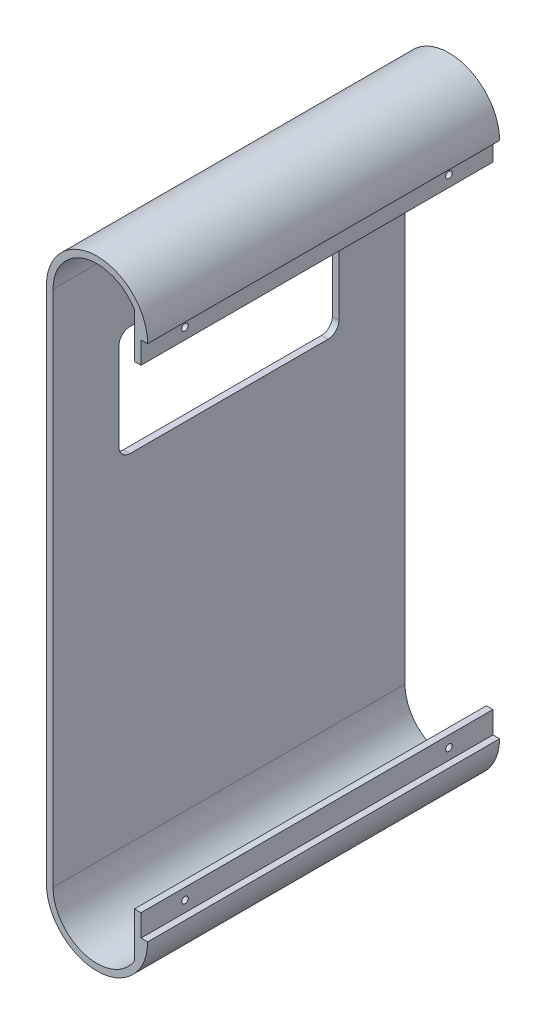
from build123d import *

# Parameters (mm, degrees)
BOSS_EXTRUDE1_DEPTH = 160
SKETCH5_W           = 3
SKETCH5_H           = 21.357816692
BOSS_EXTRUDE4_DEPTH = 160
SKETCH7_R           = 1.5
CUT_EXTRUDE2_DEPTH  = 7
CUT_EXTRUDE3_REACH  = 48


with BuildPart() as part:
    # Sketch1 → Boss-Extrude1 (new body)
    with BuildSketch(Plane.XY):
        with BuildLine():
            Line((-40, -75), (-40, 160.5))
            ThreePointArc((-40, 160.5), (-20, 180.5), (0, 160.5))
            Line((0, 160.5), (3, 160.5))
            ThreePointArc((3, 160.5), (-20, 183.5), (-43, 160.5))
            Line((-43, 160.5), (-43, -75))
            ThreePointArc((-43, -75), (-20, -98), (3, -75))
            Line((3, -75), (0, -75))
            ThreePointArc((0, -75), (-20, -95), (-40, -75))
        make_face()
    extrude(amount=-BOSS_EXTRUDE1_DEPTH)

    # Sketch5 → Boss-Extrude4 (add)
    with BuildSketch(Plane(origin=(0, 0, -160), x_dir=(-1, 0, 0), z_dir=(0, 0, -1))):
        with Locations((1.5, -75.678908346)):
            Rectangle(SKETCH5_W, SKETCH5_H)
        with Locations((1.5, 161.178908346)):
            Rectangle(SKETCH5_W, SKETCH5_H)
    extrude(amount=-BOSS_EXTRUDE4_DEPTH)

    # Sketch7 → Cut-Extrude2 (cut, through all)
    with BuildSketch(Plane.ZY.offset(3)):
        with Locations((-140, -70)):
            Circle(SKETCH7_R)
        with Locations((-20, -70)):
            Circle(SKETCH7_R)
        with Locations((-20, 155.5)):
            Circle(SKETCH7_R)
        with Locations((-140, 155.5)):
            Circle(SKETCH7_R)
    extrude(amount=-CUT_EXTRUDE2_DEPTH, mode=Mode.SUBTRACT)

    # Sketch8 → Cut-Extrude3 (cut, up to next)
    with BuildSketch(Plane.ZY.offset(43), mode=Mode.PRIVATE) as cut_extrude3_sk1:
        with BuildLine():
            Line((-125, 128.257283518), (-35, 128.257283518))
            ThreePointArc((-35, 128.257283518), (-31.464466094, 126.792817424), (-30, 123.257283518))
            Line((-30, 123.257283518), (-30, 83.257283518))
            ThreePointArc((-30, 83.257283518), (-31.464466094, 79.721749612), (-35, 78.257283518))
            Line((-35, 78.257283518), (-125, 78.257283518))
            ThreePointArc((-125, 78.257283518), (-128.535533906, 79.721749612), (-130, 83.257283518))
            Line((-130, 83.257283518), (-130, 123.257283518))
            ThreePointArc((-130, 123.257283518), (-128.535533906, 126.792817424), (-125, 128.257283518))
        make_face()
    cut_extrude3_tool1 = extrude(cut_extrude3_sk1.sketch, amount=-CUT_EXTRUDE3_REACH, mode=Mode.PRIVATE) & part.part
    add(cut_extrude3_tool1.solids().sort_by_distance((-43, 103.257284, -80))[0], mode=Mode.SUBTRACT)


solid = part.part
